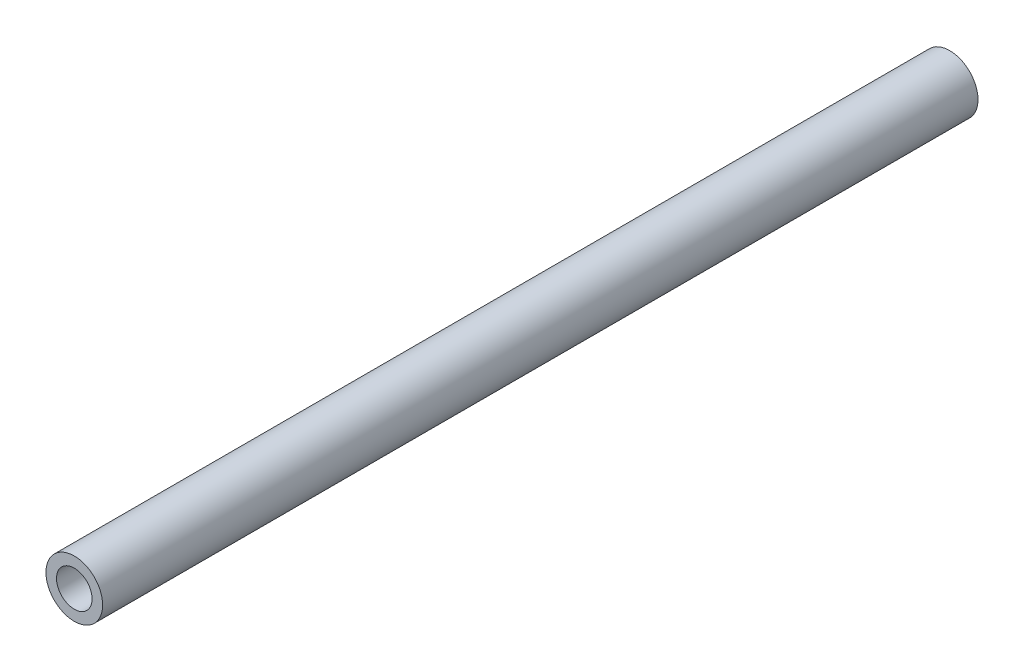
from build123d import *

# Parameters (mm, degrees)
ESQUISSE1_R             = 6.475
BOSS_EXTRU_1_DEPTH      = 200
ESQUISSE2_R             = 4.065
ENL_V_MAT_EXTRU_1_DEPTH = 201


with BuildPart() as part:
    # Esquisse1 → Boss.-Extru.1 (new body)
    with BuildSketch(Plane.XY):
        Circle(ESQUISSE1_R)
    extrude(amount=BOSS_EXTRU_1_DEPTH)

    # Esquisse2 → Enlèv. mat.-Extru.1 (cut, through all)
    with BuildSketch(Plane(origin=(0, 0, 0), x_dir=(-1, 0, 0), z_dir=(0, 0, -1))):
        Circle(ESQUISSE2_R)
    extrude(amount=-ENL_V_MAT_EXTRU_1_DEPTH, mode=Mode.SUBTRACT)


solid = part.part
